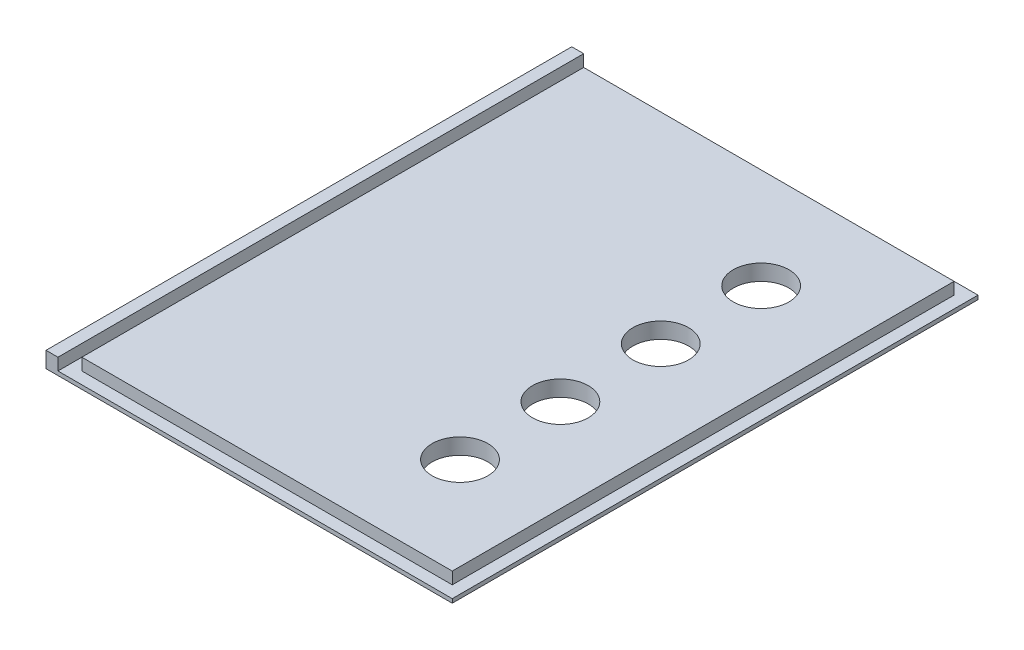
from build123d import *

# Parameters (mm, degrees)
SKETCH1_W           = 102
SKETCH1_H           = 132
BOSS_EXTRUDE2_DEPTH = 1
SKETCH2_W           = 3
SKETCH2_H           = 132
BOSS_EXTRUDE5_DEPTH = 3
SKETCH3_W           = 93
SKETCH3_H           = 126
BOSS_EXTRUDE6_DEPTH = 3
SKETCH4_R           = 7
CUT_EXTRUDE1_DEPTH  = 4


with BuildPart() as part:
    # Sketch1 → Boss-Extrude2 (new body)
    with BuildSketch(Plane(origin=(0, 0, 0), x_dir=(1, 0, 0), z_dir=(0, 1, 0))):
        Rectangle(SKETCH1_W, SKETCH1_H)
    extrude(amount=BOSS_EXTRUDE2_DEPTH)

    # Sketch2 → Boss-Extrude5 (add)
    with BuildSketch(Plane(origin=(0, 1, 0), x_dir=(1, 0, 0), z_dir=(0, 1, 0))):
        with Locations((-49.5, 0)):
            Rectangle(SKETCH2_W, SKETCH2_H)
    extrude(amount=BOSS_EXTRUDE5_DEPTH)

    # Sketch3 → Boss-Extrude6 (add)
    with BuildSketch(Plane(origin=(0, 1, 0), x_dir=(1, 0, 0), z_dir=(0, 1, 0))):
        with Locations((1.5, 0)):
            Rectangle(SKETCH3_W, SKETCH3_H)
    extrude(amount=BOSS_EXTRUDE6_DEPTH)

    # Sketch4 → Cut-Extrude1 (cut)
    with BuildSketch(Plane(origin=(0, 0, 0), x_dir=(1, 0, 0), z_dir=(0, 1, 0))):
        with Locations((24.75, 12.6)):
            Circle(SKETCH4_R)
        with Locations((24.75, -12.6)):
            Circle(SKETCH4_R)
        with Locations((24.75, 37.8)):
            Circle(SKETCH4_R)
        with Locations((24.75, -37.8)):
            Circle(SKETCH4_R)
    extrude(amount=CUT_EXTRUDE1_DEPTH, mode=Mode.SUBTRACT)


solid = part.part
